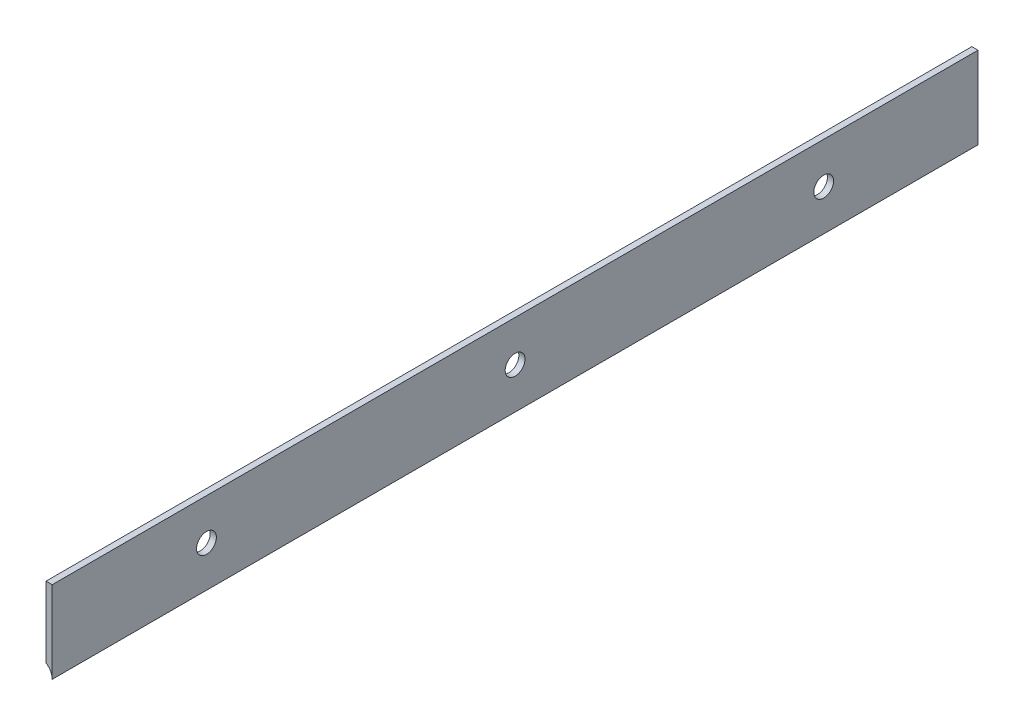
from build123d import *

# Parameters (mm, degrees)
BOSS_EXTRUDE3_DEPTH       = 152.4
F_4_CLEARANCE_HOLE2_D     = 3.2639
F_4_CLEARANCE_HOLE2_DEPTH = 1.524
F_4_CLEARANCE_HOLE2_TIP   = 0.980574487


with BuildPart() as part:
    # Sketch2 → Boss-Extrude3 (new body)
    with BuildSketch(Plane.XY):
        with BuildLine():
            Line((-0.508, -4.915254952), (-0.508, 6.746875))
            Line((-0.508, 6.746875), (0.508, 6.746875))
            Line((0.508, 6.746875), (0.508, -6.746875))
            ThreePointArc((0.508, -6.746875), (0.236990731, -5.699606171), (-0.508, -4.915254952))
        make_face()
    extrude(amount=BOSS_EXTRUDE3_DEPTH)

    # #4 Clearance Hole2
    with Locations(Plane(origin=(0.508, 0, 0), x_dir=(0, 0, -1), z_dir=(1, 0, 0))):
        with Locations((-25.4, 0), (-76.2, 0), (-177.8, 0), (-127, 0), (-228.6, 0), (-279.4, 0)):
            Hole(F_4_CLEARANCE_HOLE2_D / 2, depth=F_4_CLEARANCE_HOLE2_DEPTH)
            with Locations((0, 0, -(F_4_CLEARANCE_HOLE2_DEPTH + F_4_CLEARANCE_HOLE2_TIP / 2))):  # 118° drill point
                Cone(0, F_4_CLEARANCE_HOLE2_D / 2, F_4_CLEARANCE_HOLE2_TIP, mode=Mode.SUBTRACT)


solid = part.part
